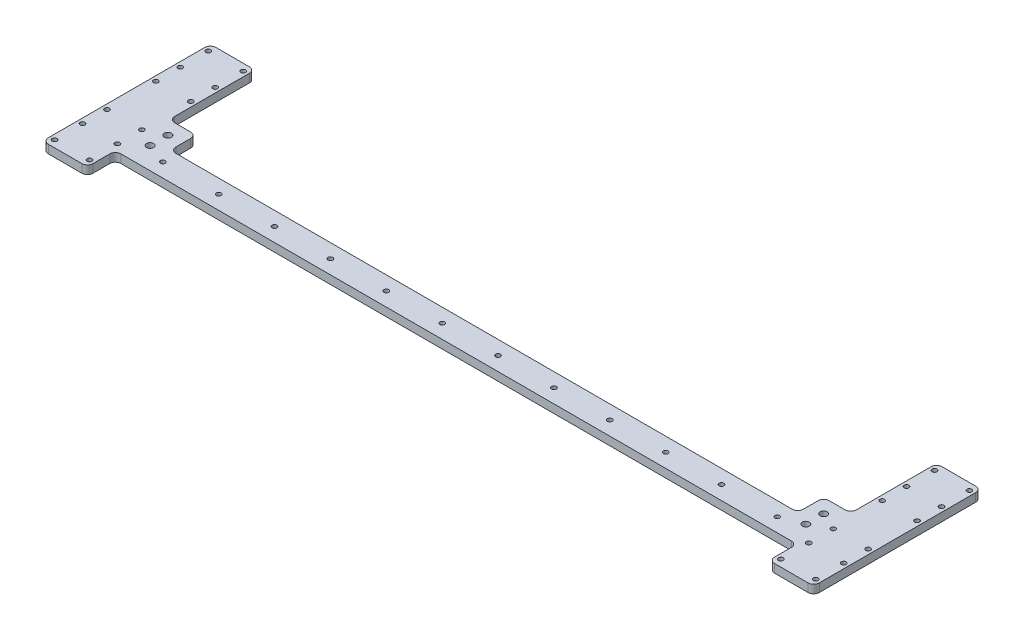
from build123d import *

# Parameters (mm, degrees)
SKETCH1_W            = 552
SKETCH1_H            = 20
BOSS_EXTRUDE1_DEPTH  = 6
SKETCH3_W            = 32
SKETCH3_H            = 120
BOSS_EXTRUDE2_DEPTH  = 6
M3_CLEARANCE_HOLE1_D = 3.4
SKETCH10_W           = 19.392395665
SKETCH10_H           = 18.526197832
SKETCH10_R           = 2.525
BOSS_EXTRUDE3_DEPTH  = 6
SKETCH12_R           = 2.525
CUT_EXTRUDE2_DEPTH   = 7
FILLET2_R            = 4
FILLET2_OF_MIRROR1_R = 4


with BuildPart() as part:
    # Sketch1 → Boss-Extrude1 (new body)
    with BuildSketch(Plane(origin=(0, 0, 0), x_dir=(1, 0, 0), z_dir=(0, 1, 0))):
        with Locations((276, 10)):
            Rectangle(SKETCH1_W, SKETCH1_H)
    extrude(amount=BOSS_EXTRUDE1_DEPTH)

    # Sketch3 → Boss-Extrude2 (add)
    with BuildSketch(Plane.XZ):
        with Locations((16, -40)):
            Rectangle(SKETCH3_W, SKETCH3_H)
    boss_extrude2 = extrude(amount=-BOSS_EXTRUDE2_DEPTH)

    # M3 Clearance Hole1 (through all)
    with Locations(Plane(origin=(0, 6, 0), x_dir=(1, 0, 0), z_dir=(0, 1, 0))):
        with Locations((3.5, -15), (3.5, 5), (28.5, 5), (28.5, -15), (3.5, 95), (28.5, 95), (28.5, 75), (3.5, 75), (56, 10), (96, 10), (136, 10), (176, 10), (216, 10), (256, 10), (28.5, 57.5), (28.5, 22.5), (3.5, 22.5), (3.5, 57.5)):
            m3_clearance_hole1 = Hole(M3_CLEARANCE_HOLE1_D / 2)

    # Sketch10 → Boss-Extrude3 (add)
    with BuildSketch(Plane(origin=(0, 6, 0), x_dir=(1, 0, 0), z_dir=(0, 1, 0))):
        with Locations((41.696197833, 29.263098916)):
            Rectangle(SKETCH10_W, SKETCH10_H)
        with Locations((41.232395665, 28.366197832)):
            Circle(SKETCH10_R, mode=Mode.SUBTRACT)
    boss_extrude3 = extrude(amount=-BOSS_EXTRUDE3_DEPTH)

    # Sketch12 → Cut-Extrude2 (cut, through all)
    with BuildSketch(Plane(origin=(0, 6, 0), x_dir=(1, 0, 0), z_dir=(0, 1, 0))):
        with Locations((41.232395665, 15.636197832)):
            Circle(SKETCH12_R)
    cut_extrude2 = extrude(amount=-CUT_EXTRUDE2_DEPTH, mode=Mode.SUBTRACT)

    # Fillet2
    fillet2_edges = [part.edges().sort_by_distance(p)[0] for p in [
        (32, 3, -38.526197832),
        (51.392395665, 3, -38.526197832),
        (51.392395665, 3, -20),
        (0, 3, -100),
        (32, 3, 20),
        (0, 3, 20),
        (32, 3, 0),
        (32, 3, -100),
    ]]
    fillet(fillet2_edges, radius=FILLET2_R)

    # Mirror1: Boss-Extrude2, M3 Clearance Hole1, Boss-Extrude3, Cut-Extrude2 across plane
    add(boss_extrude2.mirror(Plane(origin=(276, 0, 0), x_dir=(0, 0, 1), z_dir=(1, 0, 0))))
    add(m3_clearance_hole1.mirror(Plane(origin=(276, 0, 0), x_dir=(0, 0, 1), z_dir=(1, 0, 0))), mode=Mode.SUBTRACT)
    add(boss_extrude3.mirror(Plane(origin=(276, 0, 0), x_dir=(0, 0, 1), z_dir=(1, 0, 0))))
    add(cut_extrude2.mirror(Plane(origin=(276, 0, 0), x_dir=(0, 0, 1), z_dir=(1, 0, 0))), mode=Mode.SUBTRACT)

    # Fillet2 of Mirror1
    fillet2_of_mirror1_edges = [part.edges().sort_by_distance(p)[0] for p in [
        (520, 3, -38.526197832),
        (500.607604335, 3, -38.526197832),
        (500.607604335, 3, -20),
        (552, 3, -100),
        (520, 3, 20),
        (552, 3, 20),
        (520, 3, 0),
        (520, 3, -100),
    ]]
    fillet(fillet2_of_mirror1_edges, radius=FILLET2_OF_MIRROR1_R)


solid = part.part
